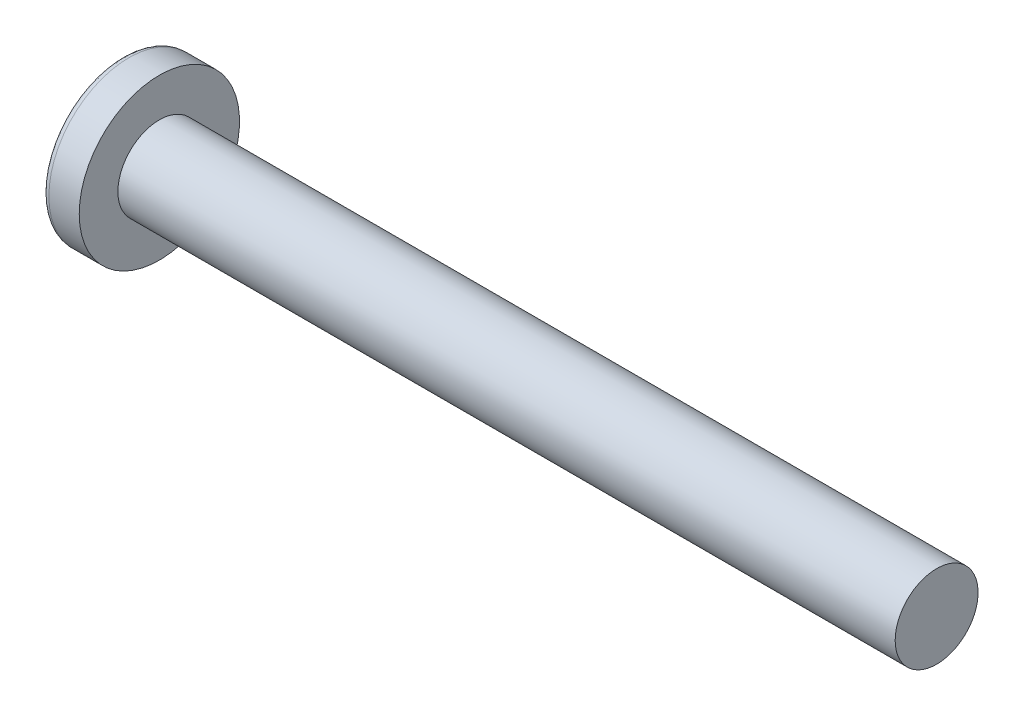
from build123d import *

# Parameters (mm, degrees)
SKETCH3_W         = 0.5588
SKETCH3_H         = 1.9304
SKETCH4_W         = 0.2794
SKETCH4_H         = 0.2794
CIRPATTERN1_COUNT = 2
CIRPATTERN1_ANGLE = 90


with BuildPart() as part:
    # BodySke → Base-Revolve (revolve)
    with BuildSketch(Plane.XY):
        with BuildLine():
            Line((1.1176, 0.762), (1.1176, 1.4732))
            Line((1.1176, 1.4732), (0.559486612, 1.4732))
            ThreePointArc((0.559486612, 1.4732), (0.501455643, 1.459166396), (0.456249613, 1.420167033))
            ThreePointArc((0.456249613, 1.420167033), (0.116862787, 0.745828082), (0, 0))
            Line((0, 0), (15.4051, 0))
            Line((15.4051, 0), (15.4051, 0.762))
            Line((15.4051, 0.762), (1.1176, 0.762))
        make_face()
    revolve(axis=Axis((-25.4, 0, 0), (1, 0, 0)))

    # Sketch3 → Cut-Loft1 section 0
    with BuildSketch(Plane(origin=(0, 0, 0), x_dir=(0, 0, -1), z_dir=(1, 0, 0))):
        Rectangle(SKETCH3_W, SKETCH3_H)
    # Sketch4 → Cut-Loft1 section 1
    with BuildSketch(Plane(origin=(0.9652, 0, 0), x_dir=(0, 0, -1), z_dir=(1, 0, 0))):
        Rectangle(SKETCH4_W, SKETCH4_H)
    cut_loft1 = loft(mode=Mode.SUBTRACT)

    # CirPattern1: Cut-Loft1 ×2 about axis
    cirpattern1_axis = Axis((0, 0, 0), (1, 0, 0))
    for i in range(1, CIRPATTERN1_COUNT):
        add(cut_loft1.rotate(cirpattern1_axis, i * CIRPATTERN1_ANGLE / (CIRPATTERN1_COUNT - 1)), mode=Mode.SUBTRACT)


solid = part.part
